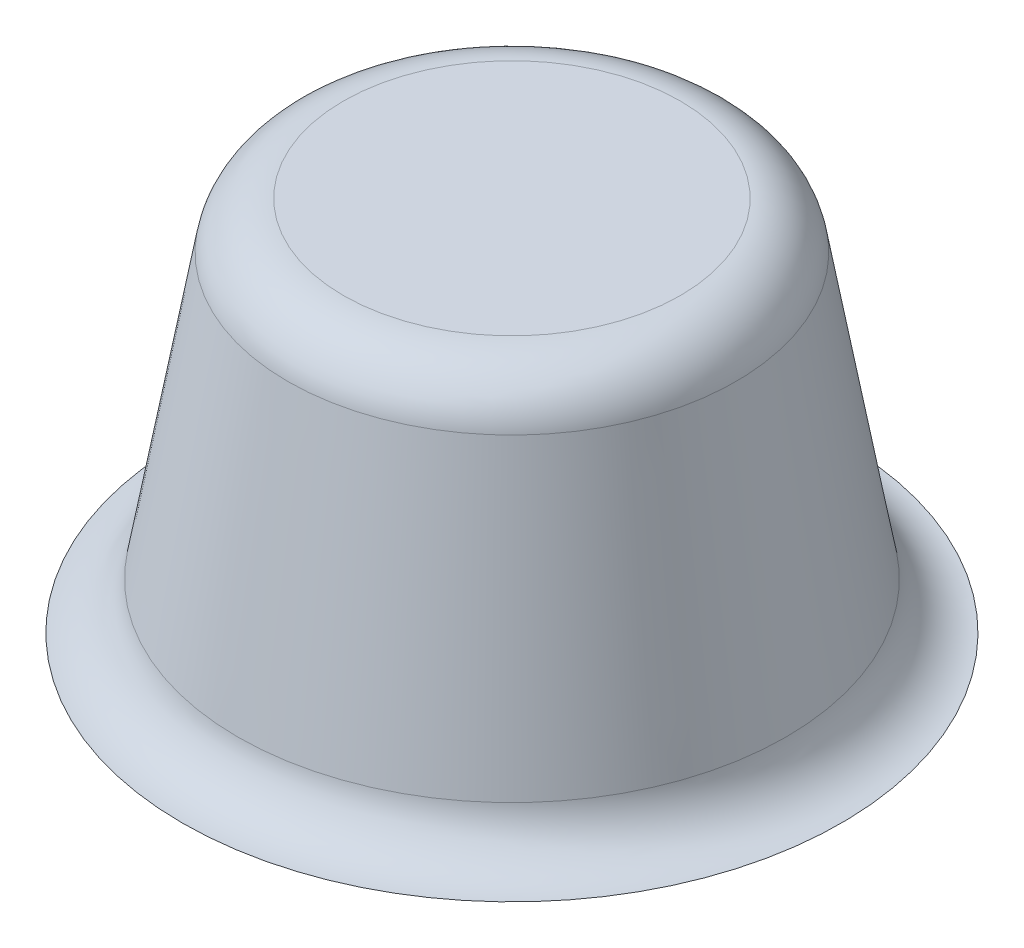
from build123d import *

# Parameters (mm, degrees)
SKETCH1_W           = 30
SKETCH1_H           = 30
BOSS_EXTRUDE1_DEPTH = 1
SKETCH2_R           = 7.5
BOSS_EXTRUDE2_DEPTH = 10
BOSS_EXTRUDE2_TAPER = 10
FILLET2_R           = 1.5


with BuildPart() as part:
    # Sketch1 → Boss-Extrude1 (new body)
    with BuildSketch(Plane(origin=(0, 0, 0), x_dir=(1, 0, 0), z_dir=(0, 1, 0))):
        Rectangle(SKETCH1_W, SKETCH1_H)
    extrude(amount=-BOSS_EXTRUDE1_DEPTH)

    # Sketch2 → Boss-Extrude2 (add)
    with BuildSketch(Plane(origin=(0, 0, 0), x_dir=(1, 0, 0), z_dir=(0, 1, 0))):
        Circle(SKETCH2_R)
    extrude(amount=BOSS_EXTRUDE2_DEPTH, taper=BOSS_EXTRUDE2_TAPER)

    # Fillet2
    fillet2_edges = [part.edges().sort_by_distance(p)[0] for p in [
        (-7.5, 0, 0),
        (-5.736730193, 10, 0),
    ]]
    fillet(fillet2_edges, radius=FILLET2_R)

    # SurfaceCut2
    split(bisect_by=Plane(origin=(0, 0, 0), x_dir=(1, 0, 0), z_dir=(0, 1, 0)), keep=Keep.TOP)


solid = part.part
